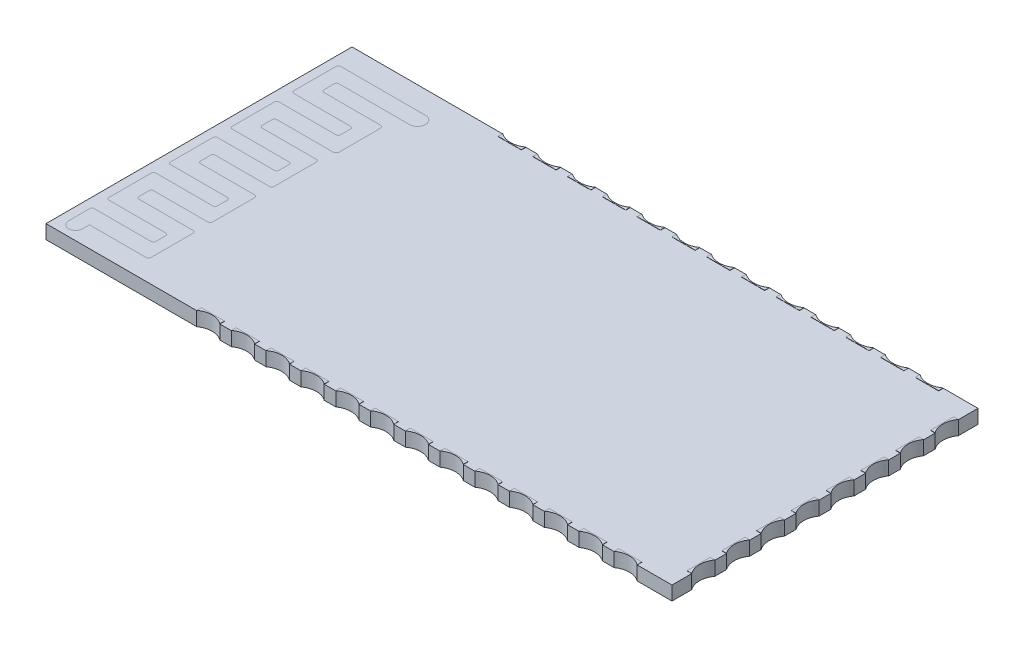
from build123d import *

# Parameters (mm, degrees)
SKETCH1_W           = 27
SKETCH1_H           = 13.2
BOSS_EXTRUDE1_DEPTH = 0.6
SKETCH3_W           = 1
SKETCH3_H           = 0.2
SKETCH3_W_2         = 0.2
SKETCH3_H_2         = 1
BOSS_EXTRUDE2_DEPTH = 0.01
CUT_EXTRUDE1_DEPTH  = 1.61


with BuildPart() as part:
    # Sketch1 → Boss-Extrude1 (new body)
    with BuildSketch(Plane(origin=(0, 0, 0), x_dir=(1, 0, 0), z_dir=(0, 1, 0))):
        Rectangle(SKETCH1_W, SKETCH1_H)
    extrude(amount=BOSS_EXTRUDE1_DEPTH)

    # Sketch3 → Boss-Extrude2 (add)
    with BuildSketch(Plane(origin=(0, 0.6, 0), x_dir=(1, 0, 0), z_dir=(0, 1, 0))):
        with Locations((-6.5, 6.5)):
            Rectangle(SKETCH3_W, SKETCH3_H)
        with Locations((-5, 6.5)):
            Rectangle(SKETCH3_W, SKETCH3_H)
        with Locations((-3.5, 6.5)):
            Rectangle(SKETCH3_W, SKETCH3_H)
        with Locations((-2, 6.5)):
            Rectangle(SKETCH3_W, SKETCH3_H)
        with Locations((-0.5, 6.5)):
            Rectangle(SKETCH3_W, SKETCH3_H)
        with Locations((1, 6.5)):
            Rectangle(SKETCH3_W, SKETCH3_H)
        with Locations((2.5, 6.5)):
            Rectangle(SKETCH3_W, SKETCH3_H)
        with Locations((4, 6.5)):
            Rectangle(SKETCH3_W, SKETCH3_H)
        with Locations((5.5, 6.5)):
            Rectangle(SKETCH3_W, SKETCH3_H)
        with Locations((7, 6.5)):
            Rectangle(SKETCH3_W, SKETCH3_H)
        with Locations((8.5, 6.5)):
            Rectangle(SKETCH3_W, SKETCH3_H)
        with Locations((10, 6.5)):
            Rectangle(SKETCH3_W, SKETCH3_H)
        with Locations((11.5, 6.5)):
            Rectangle(SKETCH3_W, SKETCH3_H)
        with Locations((13.4, 5.25)):
            Rectangle(SKETCH3_W_2, SKETCH3_H_2)
        with Locations((13.4, 3.75)):
            Rectangle(SKETCH3_W_2, SKETCH3_H_2)
        with Locations((13.4, 2.25)):
            Rectangle(SKETCH3_W_2, SKETCH3_H_2)
        with Locations((13.4, 0.75)):
            Rectangle(SKETCH3_W_2, SKETCH3_H_2)
        with Locations((13.4, -0.75)):
            Rectangle(SKETCH3_W_2, SKETCH3_H_2)
        with Locations((13.4, -2.25)):
            Rectangle(SKETCH3_W_2, SKETCH3_H_2)
        with Locations((13.4, -3.75)):
            Rectangle(SKETCH3_W_2, SKETCH3_H_2)
        with Locations((13.4, -5.25)):
            Rectangle(SKETCH3_W_2, SKETCH3_H_2)
        with Locations((11.5, -6.5)):
            Rectangle(SKETCH3_W, SKETCH3_H)
        with Locations((10, -6.5)):
            Rectangle(SKETCH3_W, SKETCH3_H)
        with Locations((8.5, -6.5)):
            Rectangle(SKETCH3_W, SKETCH3_H)
        with Locations((7, -6.5)):
            Rectangle(SKETCH3_W, SKETCH3_H)
        with Locations((5.5, -6.5)):
            Rectangle(SKETCH3_W, SKETCH3_H)
        with Locations((4, -6.5)):
            Rectangle(SKETCH3_W, SKETCH3_H)
        with Locations((2.5, -6.5)):
            Rectangle(SKETCH3_W, SKETCH3_H)
        with Locations((1, -6.5)):
            Rectangle(SKETCH3_W, SKETCH3_H)
        with Locations((-0.5, -6.5)):
            Rectangle(SKETCH3_W, SKETCH3_H)
        with Locations((-2, -6.5)):
            Rectangle(SKETCH3_W, SKETCH3_H)
        with Locations((-3.5, -6.5)):
            Rectangle(SKETCH3_W, SKETCH3_H)
        with Locations((-5, -6.5)):
            Rectangle(SKETCH3_W, SKETCH3_H)
        with Locations((-6.5, -6.5)):
            Rectangle(SKETCH3_W, SKETCH3_H)
    extrude(amount=BOSS_EXTRUDE2_DEPTH)

    # Sketch4 → Cut-Extrude1 (cut, through all)
    with BuildSketch(Plane(origin=(0, 0.61, 0), x_dir=(1, 0, 0), z_dir=(0, 1, 0))):
        with BuildLine():
            Line((-7, 6.6), (-6, 6.6))
            ThreePointArc((-6, 6.6), (-6.5, 6.437386354), (-7, 6.6))
        make_face()
        with BuildLine():
            Line((-5.5, 6.6), (-4.5, 6.6))
            ThreePointArc((-4.5, 6.6), (-5, 6.437386354), (-5.5, 6.6))
        make_face()
        with BuildLine():
            Line((-4, 6.6), (-3, 6.6))
            ThreePointArc((-3, 6.6), (-3.5, 6.437386354), (-4, 6.6))
        make_face()
        with BuildLine():
            Line((-2.5, 6.6), (-1.5, 6.6))
            ThreePointArc((-1.5, 6.6), (-2, 6.437386354), (-2.5, 6.6))
        make_face()
        with BuildLine():
            Line((-1, 6.6), (0, 6.6))
            ThreePointArc((0, 6.6), (-0.5, 6.437386354), (-1, 6.6))
        make_face()
        with BuildLine():
            Line((0.5, 6.6), (1.5, 6.6))
            ThreePointArc((1.5, 6.6), (1, 6.437386354), (0.5, 6.6))
        make_face()
        with BuildLine():
            Line((2, 6.6), (3, 6.6))
            ThreePointArc((3, 6.6), (2.5, 6.437386354), (2, 6.6))
        make_face()
        with BuildLine():
            Line((3.5, 6.6), (4.5, 6.6))
            ThreePointArc((4.5, 6.6), (4, 6.437386354), (3.5, 6.6))
        make_face()
        with BuildLine():
            Line((5, 6.6), (6, 6.6))
            ThreePointArc((6, 6.6), (5.5, 6.437386354), (5, 6.6))
        make_face()
        with BuildLine():
            Line((6.5, 6.6), (7.5, 6.6))
            ThreePointArc((7.5, 6.6), (7, 6.437386354), (6.5, 6.6))
        make_face()
        with BuildLine():
            Line((8, 6.6), (9, 6.6))
            ThreePointArc((9, 6.6), (8.5, 6.437386354), (8, 6.6))
        make_face()
        with BuildLine():
            Line((9.5, 6.6), (10.5, 6.6))
            ThreePointArc((10.5, 6.6), (10, 6.437386354), (9.5, 6.6))
        make_face()
        with BuildLine():
            Line((11, 6.6), (12, 6.6))
            ThreePointArc((12, 6.6), (11.5, 6.437386354), (11, 6.6))
        make_face()
        with BuildLine():
            Line((13.5, 5.75), (13.5, 4.75))
            ThreePointArc((13.5, 4.75), (13.337386354, 5.25), (13.5, 5.75))
        make_face()
        with BuildLine():
            Line((13.5, 4.25), (13.5, 3.25))
            ThreePointArc((13.5, 3.25), (13.337386354, 3.75), (13.5, 4.25))
        make_face()
        with BuildLine():
            Line((13.5, 2.75), (13.5, 1.75))
            ThreePointArc((13.5, 1.75), (13.337386354, 2.25), (13.5, 2.75))
        make_face()
        with BuildLine():
            Line((13.5, 1.25), (13.5, 0.25))
            ThreePointArc((13.5, 0.25), (13.337386354, 0.75), (13.5, 1.25))
        make_face()
        with BuildLine():
            Line((13.5, -0.25), (13.5, -1.25))
            ThreePointArc((13.5, -1.25), (13.337386354, -0.75), (13.5, -0.25))
        make_face()
        with BuildLine():
            Line((13.5, -1.75), (13.5, -2.75))
            ThreePointArc((13.5, -2.75), (13.337386354, -2.25), (13.5, -1.75))
        make_face()
        with BuildLine():
            Line((13.5, -3.25), (13.5, -4.25))
            ThreePointArc((13.5, -4.25), (13.337386354, -3.75), (13.5, -3.25))
        make_face()
        with BuildLine():
            Line((13.5, -4.75), (13.5, -5.75))
            ThreePointArc((13.5, -5.75), (13.337386354, -5.25), (13.5, -4.75))
        make_face()
        with BuildLine():
            Line((11, -6.6), (12, -6.6))
            ThreePointArc((12, -6.6), (11.5, -6.437386354), (11, -6.6))
        make_face()
        with BuildLine():
            Line((9.5, -6.6), (10.5, -6.6))
            ThreePointArc((10.5, -6.6), (10, -6.437386354), (9.5, -6.6))
        make_face()
        with BuildLine():
            Line((8, -6.6), (9, -6.6))
            ThreePointArc((9, -6.6), (8.5, -6.437386354), (8, -6.6))
        make_face()
        with BuildLine():
            Line((6.5, -6.6), (7.5, -6.6))
            ThreePointArc((7.5, -6.6), (7, -6.437386354), (6.5, -6.6))
        make_face()
        with BuildLine():
            Line((5, -6.6), (6, -6.6))
            ThreePointArc((6, -6.6), (5.5, -6.437386354), (5, -6.6))
        make_face()
        with BuildLine():
            Line((3.5, -6.6), (4.5, -6.6))
            ThreePointArc((4.5, -6.6), (4, -6.437386354), (3.5, -6.6))
        make_face()
        with BuildLine():
            Line((2, -6.6), (3, -6.6))
            ThreePointArc((3, -6.6), (2.5, -6.437386354), (2, -6.6))
        make_face()
        with BuildLine():
            Line((0.5, -6.6), (1.5, -6.6))
            ThreePointArc((1.5, -6.6), (1, -6.437386354), (0.5, -6.6))
        make_face()
        with BuildLine():
            Line((-1, -6.6), (0, -6.6))
            ThreePointArc((0, -6.6), (-0.5, -6.437386354), (-1, -6.6))
        make_face()
        with BuildLine():
            Line((-2.5, -6.6), (-1.5, -6.6))
            ThreePointArc((-1.5, -6.6), (-2, -6.437386354), (-2.5, -6.6))
        make_face()
        with BuildLine():
            Line((-4, -6.6), (-3, -6.6))
            ThreePointArc((-3, -6.6), (-3.5, -6.437386354), (-4, -6.6))
        make_face()
        with BuildLine():
            Line((-5.5, -6.6), (-4.5, -6.6))
            ThreePointArc((-4.5, -6.6), (-5, -6.437386354), (-5.5, -6.6))
        make_face()
        with BuildLine():
            Line((-7, -6.6), (-6, -6.6))
            ThreePointArc((-6, -6.6), (-6.5, -6.437386354), (-7, -6.6))
        make_face()
    extrude(amount=-CUT_EXTRUDE1_DEPTH, mode=Mode.SUBTRACT)


solid = part.part
